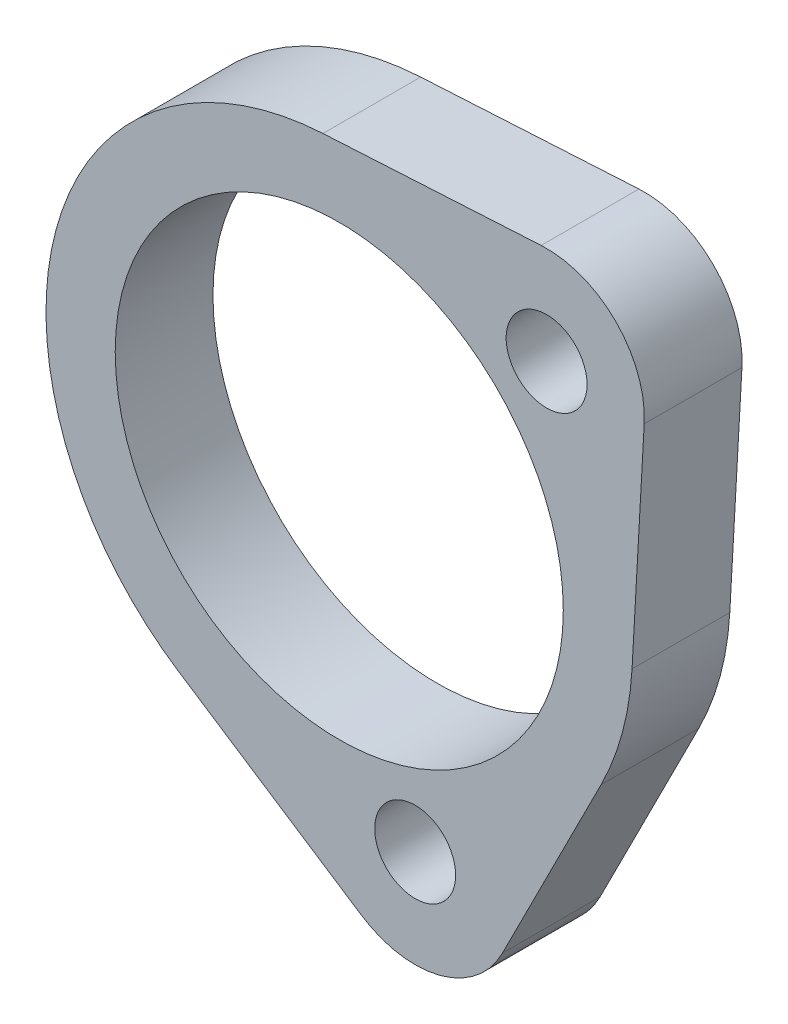
from build123d import *

# Parameters (mm, degrees)
SKETCH1_R           = 14.5542
SKETCH1_R_2         = 2.6289
BOSS_EXTRUDE1_DEPTH = 6.35


with BuildPart() as part:
    # Sketch1 → Boss-Extrude1 (new body)
    with BuildSketch(Plane.XY):
        with BuildLine():
            Line((-10.428209513, -15.942237809), (1.454432972, -23.71496626))
            ThreePointArc((1.454432972, -23.71496626), (6.574003746, -24.534515988), (10.597907229, -21.264979717))
            Line((10.597907229, -21.264979717), (17.002213259, -8.592278179))
            ThreePointArc((17.002213259, -8.592278179), (18.400886991, -4.930502809), (19.020487692, -1.05997545))
            Line((19.020487692, -1.05997545), (19.810546746, 13.117059032))
            ThreePointArc((19.810546746, 13.117059032), (17.960512242, 17.960512242), (13.117059032, 19.810546746))
            Line((13.117059032, 19.810546746), (-1.05997545, 19.020487692))
            ThreePointArc((-1.05997545, 19.020487692), (-18.400886991, 4.930502809), (-10.428209513, -15.942237809))
        make_face()
        Circle(SKETCH1_R, mode=Mode.SUBTRACT)
        with Locations((4.930502809, -18.400886991)):
            Circle(SKETCH1_R_2, mode=Mode.SUBTRACT)
        with Locations((13.470384182, 13.470384182)):
            Circle(SKETCH1_R_2, mode=Mode.SUBTRACT)
    extrude(amount=BOSS_EXTRUDE1_DEPTH)


solid = part.part
